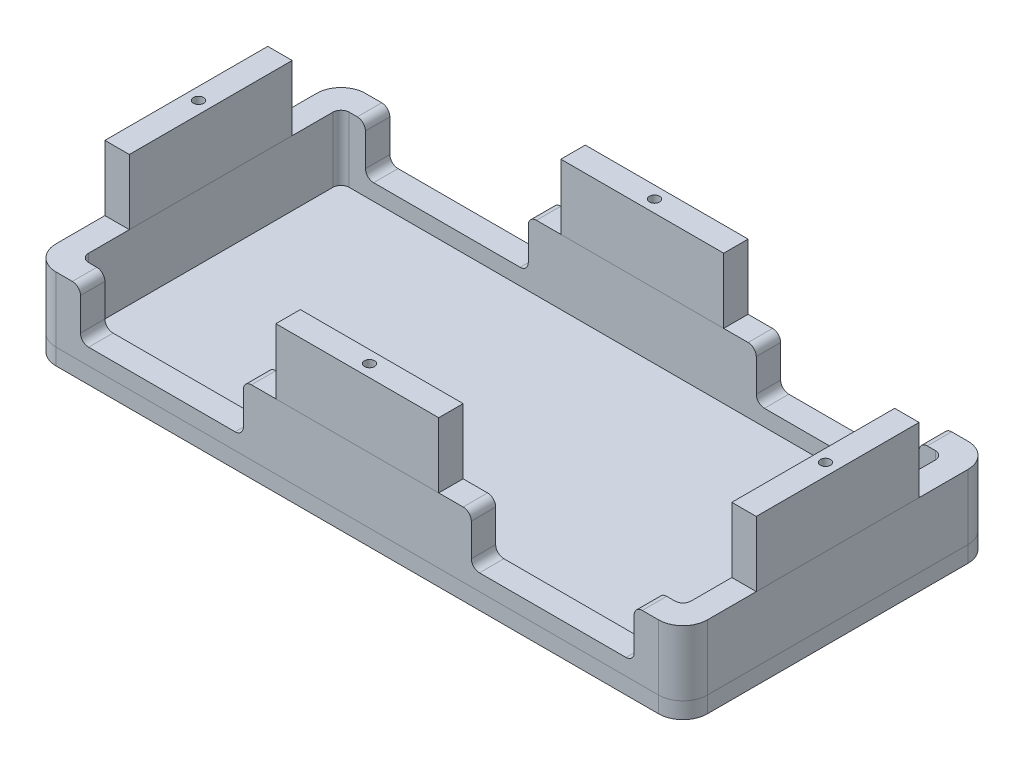
from build123d import *

# Parameters (mm, degrees)
SKETCH1_W                         = 80
SKETCH1_H                         = 38
SKETCH1_W_2                       = 74
SKETCH1_H_2                       = 32
BOSS_EXTRUDE1_DEPTH               = 8
SKETCH1_4_W                       = 20
SKETCH1_4_H                       = 3
BOSS_EXTRUDE4_DEPTH               = 8
SKETCH1_4_W_2                     = 3
SKETCH1_4_H_2                     = 20
BOSS_EXTRUDE4_2_DEPTH             = 8
BOSS_EXTRUDE4_3_DEPTH             = 8
BOSS_EXTRUDE4_4_DEPTH             = 8
SKETCH2_W                         = 80
SKETCH2_H                         = 38
BOSS_EXTRUDE2_DEPTH               = 2
FILLET2_R                         = 3
FILLET1_R                         = 3
FILLET3_R                         = 1
CUT_EXTRUDE1_DEPTH                = 57.071383076
CUT_EXTRUDE1_DEPTH_BACK           = 57.071383076
SKETCH4_W                         = 20
SKETCH4_H                         = 6
FILLET4_R                         = 1
M1_6X0_35_TAPPED_HOLE1_AT_2_COUNT = 2
M1_6X0_35_TAPPED_HOLE1_AT_2_PITCH = 42.290660908
M1_6X0_35_TAPPED_HOLE1_AT_3_COUNT = 2
M1_6X0_35_TAPPED_HOLE1_AT_3_PITCH = 42.290660908
M1_6X0_35_TAPPED_HOLE1_AT_4_COUNT = 2
M1_6X0_35_TAPPED_HOLE1_AT_4_PITCH = 77


with BuildPart() as part:
    # Sketch1 → Boss-Extrude1 (new body)
    with BuildSketch(Plane(origin=(0, 0, 0), x_dir=(1, 0, 0), z_dir=(0, 1, 0))):
        Rectangle(SKETCH1_W, SKETCH1_H)
        Rectangle(SKETCH1_W_2, SKETCH1_H_2, mode=Mode.SUBTRACT)
    extrude(amount=-BOSS_EXTRUDE1_DEPTH)

    # Fillet1
    fillet1_edges = [part.edges().sort_by_distance(p)[0] for p in [
        (-40, -4, -19),
        (40, -4, -19),
        (40, -4, 19),
        (-40, -4, 19),
    ]]
    fillet(fillet1_edges, radius=FILLET1_R)

    # Fillet3
    fillet3_edges = [part.edges().sort_by_distance(p)[0] for p in [
        (37, -4, -16),
        (37, -4, 16),
        (-37, -4, -16),
        (-37, -4, 16),
    ]]
    fillet(fillet3_edges, radius=FILLET3_R)

    # Sketch4 → Cut-Extrude1 (cut, two sides: drawn at the far end of the back side and taken through both)
    with BuildSketch(Plane.XY.offset(19).offset(-CUT_EXTRUDE1_DEPTH_BACK)):
        with Locations((-24, -3)):
            Rectangle(SKETCH4_W, SKETCH4_H)
        with Locations((24, -3)):
            Rectangle(SKETCH4_W, SKETCH4_H)
    extrude(amount=CUT_EXTRUDE1_DEPTH + CUT_EXTRUDE1_DEPTH_BACK, mode=Mode.SUBTRACT)

    # Fillet4
    fillet4_edges = [part.edges().sort_by_distance(p)[0] for p in [
        (14, -6, -17.5),
        (-34, -6, -17.5),
        (-14, -6, -17.5),
        (34, -6, -17.5),
        (34, 0, -17.5),
        (14, 0, -17.5),
        (34, 0, 17.5),
        (34, -6, 17.5),
        (14, -6, 17.5),
        (14, 0, 17.5),
        (-14, 0, 17.5),
        (-14, -6, 17.5),
        (-34, -6, 17.5),
        (-34, 0, 17.5),
        (-14, 0, -17.5),
        (-34, 0, -17.5),
    ]]
    fillet(fillet4_edges, radius=FILLET4_R)


with BuildPart() as body_2:
    # Sketch1_4 → Boss-Extrude4 (new body)
    with BuildSketch(Plane(origin=(0, 0, 0), x_dir=(1, 0, 0), z_dir=(0, 1, 0))):
        with Locations((0, 17.5)):
            Rectangle(SKETCH1_4_W, SKETCH1_4_H)
    extrude(amount=BOSS_EXTRUDE4_DEPTH)


with BuildPart() as body_3:
    # Sketch1_4 → Boss-Extrude4 2 (new body)
    with BuildSketch(Plane(origin=(0, 0, 0), x_dir=(1, 0, 0), z_dir=(0, 1, 0))):
        with Locations((-38.5, 0)):
            Rectangle(SKETCH1_4_W_2, SKETCH1_4_H_2)
    extrude(amount=BOSS_EXTRUDE4_2_DEPTH)


with BuildPart() as body_4:
    # Sketch1_4 → Boss-Extrude4 3 (new body)
    with BuildSketch(Plane(origin=(0, 0, 0), x_dir=(1, 0, 0), z_dir=(0, 1, 0))):
        with Locations((38.5, 0)):
            Rectangle(SKETCH1_4_W_2, SKETCH1_4_H_2)
    extrude(amount=BOSS_EXTRUDE4_3_DEPTH)

    # Sketch6 → M1.6x0.35 Tapped Hole1 (revolve, cut)
    with BuildSketch(Plane(origin=(38.5, 8, 0), x_dir=(0, 0, 1), z_dir=(1, 0, 0))):
        Polygon((0, 0), (0, 3.625537887), (0.625, 3.25), (0.625, 0), align=None)
    m1_6x0_35_tapped_hole1 = revolve(axis=Axis((38.5, 14.35, 0), (0, -1, 0)), mode=Mode.SUBTRACT)


with BuildPart() as body_5:
    # Sketch1_4 → Boss-Extrude4 4 (new body)
    with BuildSketch(Plane(origin=(0, 0, 0), x_dir=(1, 0, 0), z_dir=(0, 1, 0))):
        with Locations((0, -17.5)):
            Rectangle(SKETCH1_4_W, SKETCH1_4_H)
    extrude(amount=BOSS_EXTRUDE4_4_DEPTH)

    # M1.6x0.35 Tapped Hole1 at 3: M1.6x0.35 Tapped Hole1 ×2
    with Locations(*[Vector(-0.9103664774626048, 0, 0.41380294430118403) * (i * M1_6X0_35_TAPPED_HOLE1_AT_3_PITCH) for i in range(1, M1_6X0_35_TAPPED_HOLE1_AT_3_COUNT)]):
        add(m1_6x0_35_tapped_hole1, mode=Mode.SUBTRACT)


with BuildPart() as body_6:
    # Sketch2 → Boss-Extrude2 (new body)
    with BuildSketch(Plane.XZ.offset(8)):
        Rectangle(SKETCH2_W, SKETCH2_H)
    extrude(amount=BOSS_EXTRUDE2_DEPTH)

    # Fillet2
    fillet2_edges = [body_6.edges().sort_by_distance(p)[0] for p in [
        (40, -9, -19),
        (40, -9, 19),
        (-40, -9, -19),
        (-40, -9, 19),
    ]]
    fillet(fillet2_edges, radius=FILLET2_R)


with BuildPart() as body_2_1:
    add(body_2.part)

    # M1.6x0.35 Tapped Hole1 at 2: M1.6x0.35 Tapped Hole1 ×2
    with Locations(*[Vector(-0.9103664774626048, 0, -0.41380294430118403) * (i * M1_6X0_35_TAPPED_HOLE1_AT_2_PITCH) for i in range(1, M1_6X0_35_TAPPED_HOLE1_AT_2_COUNT)]):
        add(m1_6x0_35_tapped_hole1, mode=Mode.SUBTRACT)


with BuildPart() as body_3_1:
    add(body_3.part)

    # M1.6x0.35 Tapped Hole1 at 4: M1.6x0.35 Tapped Hole1 ×2
    with Locations(*[(-i * M1_6X0_35_TAPPED_HOLE1_AT_4_PITCH, 0, 0) for i in range(1, M1_6X0_35_TAPPED_HOLE1_AT_4_COUNT)]):
        add(m1_6x0_35_tapped_hole1, mode=Mode.SUBTRACT)


solid = Compound([part.part, body_4.part, body_5.part, body_6.part, body_2_1.part, body_3_1.part])
